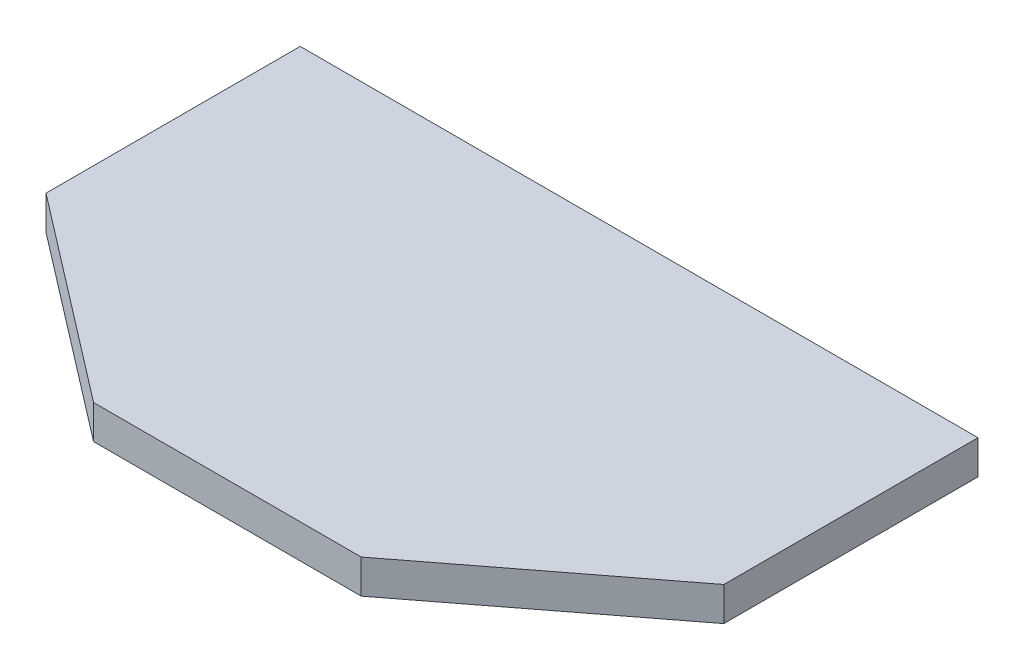
from build123d import *

# Parameters (mm, degrees)
BOSS_EXTRUDE1_DEPTH = 2.54


with BuildPart() as part:
    # Sketch1 → Boss-Extrude1 (new body)
    with BuildSketch(Plane(origin=(0, 0, 0), x_dir=(1, 0, 0), z_dir=(0, 1, 0))):
        Polygon((0, 0), (-10.029586489, 0), (-25.4, 11.806048679), (-25.4, 19.05), (-25.4, 30.856048679), (25.4, 30.856048679), (25.4, 19.05), (25.4, 11.806048679), (10.029586489, 0), align=None)
    extrude(amount=-BOSS_EXTRUDE1_DEPTH)


solid = part.part
